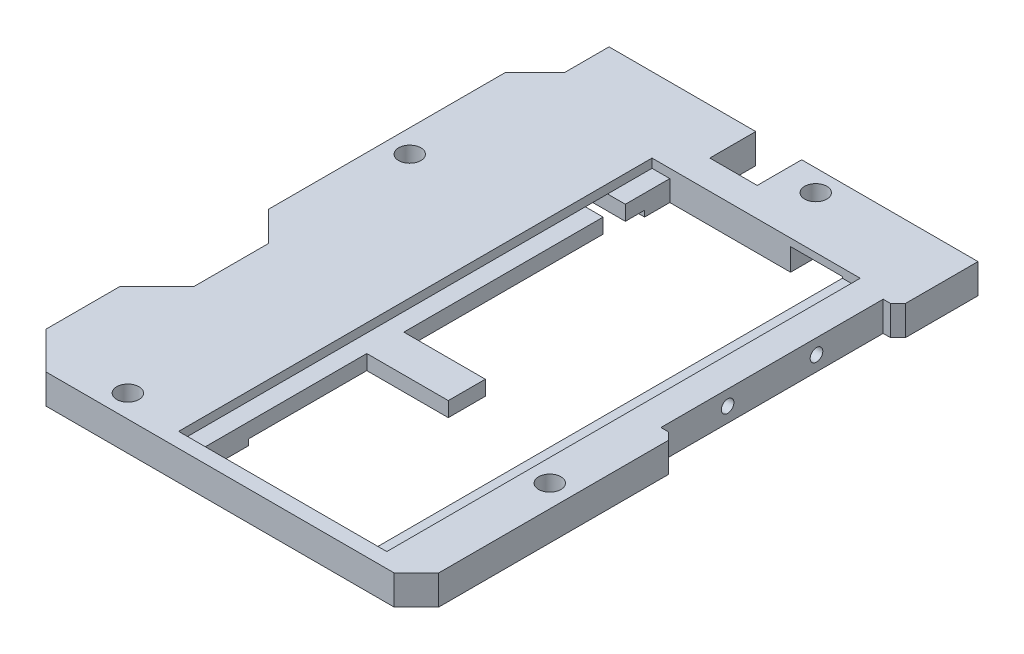
from build123d import *

# Parameters (mm, degrees)
SKETCH_1_W           = 50
SKETCH_1_H           = 76
EXTRUDE_1_DEPTH      = 4
EXTRUDE_2_DEPTH      = 4
SKETCH_4_W           = 6.4
SKETCH_4_H           = 6.2
CUT_EXTRUDE_1_DEPTH  = 4
CHAMFER_1_SIZE       = 3
SKETCH_6_W           = 2
SKETCH_6_H           = 30
CUT_EXTRUDE_3_DEPTH  = 5
SKETCH_7_W           = 28.1
SKETCH_7_H           = 63.9
CUT_EXTRUDE_4_DEPTH  = 1.2
CUT_EXTRUDE_5_DEPTH  = 3.8
CUT_EXTRUDE_6_DEPTH  = 0.8
SKETCH_10_R          = 0.85
CUT_EXTRUDE_7_DEPTH  = 3
SKETCH_11_R          = 1.5
CUT_EXTRUDE_8_DEPTH  = 5
CHAMFER_2_SIZE       = 1
SKETCH_12_W          = 7
SKETCH_12_H          = 10.1
CUT_EXTRUDE_9_DEPTH  = 3
CHAMFER_3_SIZE       = 0.2
CUT_EXTRUDE_10_DEPTH = 2


with BuildPart() as part:
    # 草图1 → 凸台-拉伸1 (new body)
    with BuildSketch(Plane(origin=(0, 0, 0), x_dir=(1, 0, 0), z_dir=(0, 1, 0))):
        with Locations((25, 38)):
            Rectangle(SKETCH_1_W, SKETCH_1_H)
    extrude(amount=EXTRUDE_1_DEPTH)

    # 草图3 → 凸台-拉伸2 (add)
    with BuildSketch(Plane(origin=(0, 4, 0), x_dir=(1, 0, 0), z_dir=(0, 1, 0))):
        Polygon((0, 0), (-5, 5), (-5, 15), (0, 20), align=None)
        Polygon((0, 30), (-4, 34), (-4, 66), (0, 70), align=None)
    extrude(amount=-EXTRUDE_2_DEPTH)

    # 草图4 → 切除-拉伸1 (cut)
    with BuildSketch(Plane(origin=(0, 4, 0), x_dir=(1, 0, 0), z_dir=(0, 1, 0))):
        with Locations((23, 72.9)):
            Rectangle(SKETCH_4_W, SKETCH_4_H)
    extrude(amount=-CUT_EXTRUDE_1_DEPTH, mode=Mode.SUBTRACT)

    # 倒角1
    chamfer_1_edges = [part.edges().sort_by_distance(p)[0] for p in [
        (50, 2, 0),
    ]]
    chamfer(chamfer_1_edges, length=CHAMFER_1_SIZE)

    # 草图6 → 切除-拉伸3 (cut, through all)
    with BuildSketch(Plane(origin=(0, 4, 0), x_dir=(1, 0, 0), z_dir=(0, 1, 0))):
        with Locations((49, 50)):
            Rectangle(SKETCH_6_W, SKETCH_6_H)
    extrude(amount=-CUT_EXTRUDE_3_DEPTH, mode=Mode.SUBTRACT)

    # 草图7 → 切除-拉伸4 (cut)
    with BuildSketch(Plane(origin=(0, 4, 0), x_dir=(1, 0, 0), z_dir=(0, 1, 0))):
        with Locations((29.95, 33.95)):
            Rectangle(SKETCH_7_W, SKETCH_7_H)
    extrude(amount=-CUT_EXTRUDE_4_DEPTH, mode=Mode.SUBTRACT)

    # 草图8 → 切除-拉伸5 (cut, through all)
    with BuildSketch(Plane(origin=(0, 2.8, 0), x_dir=(1, 0, 0), z_dir=(0, 1, 0))):
        Polygon((41.6, 65.9), (41.6, 2), (18.3, 2), (18.3, 25), (29.3, 25), (29.3, 30), (18.3, 30), (18.3, 65.9), align=None)
    extrude(amount=-CUT_EXTRUDE_5_DEPTH, mode=Mode.SUBTRACT)

    # 草图9 → 切除-拉伸6 (cut)
    with BuildSketch(Plane.XZ):
        Polygon((18.3, -25), (18.3, -9), (2.4, -9), (2.4, -61), (4.4, -61), (4.4, -62.5), (5.8, -62.5), (5.8, -67.4), (15.2, -67.4), (15.2, -62.5), (18.3, -62.5), (18.3, -30), (29.3, -30), (29.3, -25), align=None)
    extrude(amount=-CUT_EXTRUDE_6_DEPTH, mode=Mode.SUBTRACT)

    # 草图10 → 切除-拉伸7 (cut)
    with BuildSketch(Plane(origin=(48, 0, 0), x_dir=(0, 0, -1), z_dir=(1, 0, 0))):
        with Locations((44, 2)):
            Circle(SKETCH_10_R)
        with Locations((56, 2)):
            Circle(SKETCH_10_R)
    extrude(amount=-CUT_EXTRUDE_7_DEPTH, mode=Mode.SUBTRACT)

    # 草图11 → 切除-拉伸8 (cut, through all)
    with BuildSketch(Plane(origin=(0, 4, 0), x_dir=(1, 0, 0), z_dir=(0, 1, 0))):
        with Locations((-0.9, 50)):
            Circle(SKETCH_11_R)
        with Locations((31, 72.9)):
            Circle(SKETCH_11_R)
        with Locations((8, 3.05)):
            Circle(SKETCH_11_R)
        with Locations((47, 21)):
            Circle(SKETCH_11_R)
    extrude(amount=-CUT_EXTRUDE_8_DEPTH, mode=Mode.SUBTRACT)

    # 倒角2
    chamfer_2_edges = [part.edges().sort_by_distance(p)[0] for p in [
        (50, 2, -65),
        (50, 2, -35),
    ]]
    chamfer(chamfer_2_edges, length=CHAMFER_2_SIZE)

    # 草图12 → 切除-拉伸9 (cut)
    with BuildSketch(Plane.XZ):
        with Locations((38.1, -70.95)):
            Rectangle(SKETCH_12_W, SKETCH_12_H)
    extrude(amount=-CUT_EXTRUDE_9_DEPTH, mode=Mode.SUBTRACT)

    # 倒角3
    chamfer_3_edges = [part.edges().sort_by_distance(p)[0] for p in [
        (26.2, 2, -76),
        (45.8, 0, -76),
        (50, 2, -76),
        (38.1, 4, -76),
    ]]
    chamfer(chamfer_3_edges, length=CHAMFER_3_SIZE)

    # 草图13 → 切除-拉伸10 (cut)
    with BuildSketch(Plane.XZ.offset(-0.8)):
        Polygon((5.8, -67.4), (15.2, -67.4), (15.2, -65.4), (12.2, -65.4), (12.2, -59.9), (18.3, -59.9), (18.3, -56.9), (8.8, -56.9), (8.8, -59.955757414), (8.8, -65.4), (5.8, -65.4), align=None)
    extrude(amount=-CUT_EXTRUDE_10_DEPTH, mode=Mode.SUBTRACT)


solid = part.part
